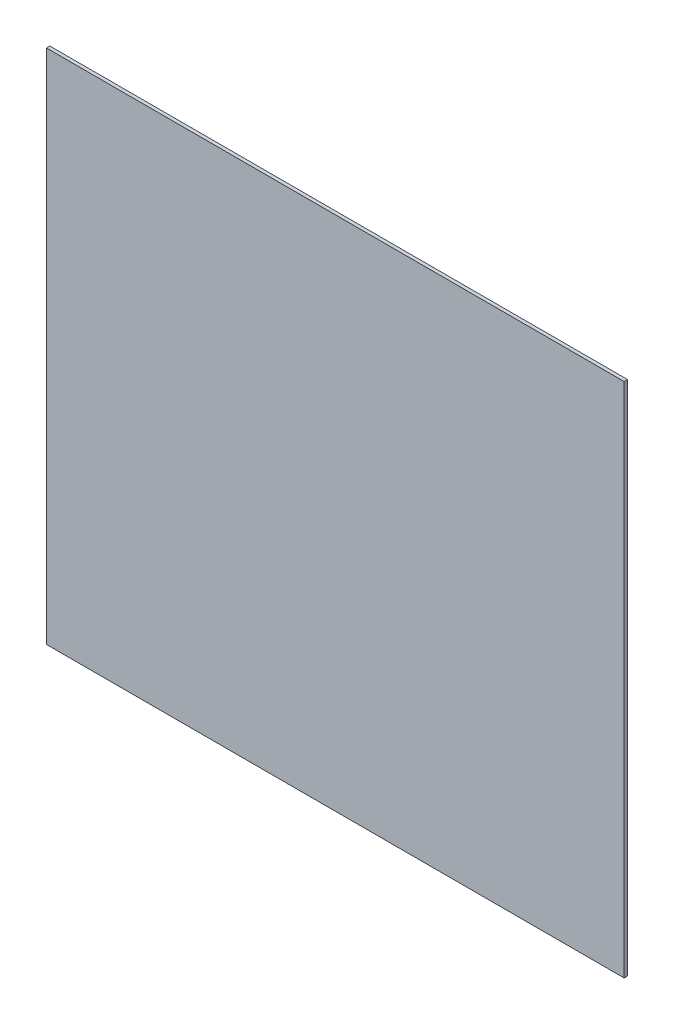
from build123d import *

# Parameters (mm, degrees)
SKETCH1_3_W         = 340
SKETCH1_3_H         = 304
BOSS_EXTRUDE2_DEPTH = 2


with BuildPart() as part:
    # Sketch1_3 → Boss-Extrude2 (new body)
    with BuildSketch(Plane.XY):
        Rectangle(SKETCH1_3_W, SKETCH1_3_H)
    extrude(amount=BOSS_EXTRUDE2_DEPTH)


solid = part.part
